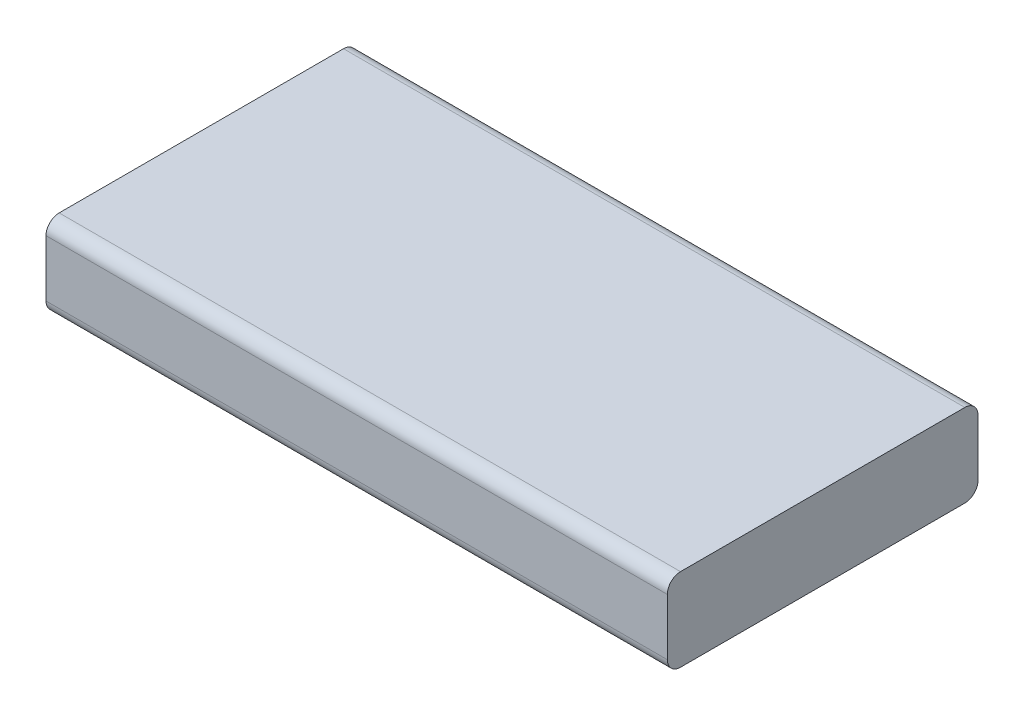
from build123d import *

# Parameters (mm, degrees)
SKETCH1_W           = 30
SKETCH1_H           = 15
BOSS_EXTRUDE1_DEPTH = 4
FILLET1_R           = 0.635


with BuildPart() as part:
    # Sketch1 → Boss-Extrude1 (new body)
    with BuildSketch(Plane(origin=(0, 0, 0), x_dir=(1, 0, 0), z_dir=(0, 1, 0))):
        with Locations((15, 7.5)):
            Rectangle(SKETCH1_W, SKETCH1_H)
    extrude(amount=BOSS_EXTRUDE1_DEPTH)

    # Fillet1
    fillet1_edges = [part.edges().sort_by_distance(p)[0] for p in [
        (15, 4, -15),
        (15, 0, -15),
        (15, 0, 0),
        (15, 4, 0),
    ]]
    fillet(fillet1_edges, radius=FILLET1_R)


solid = part.part
